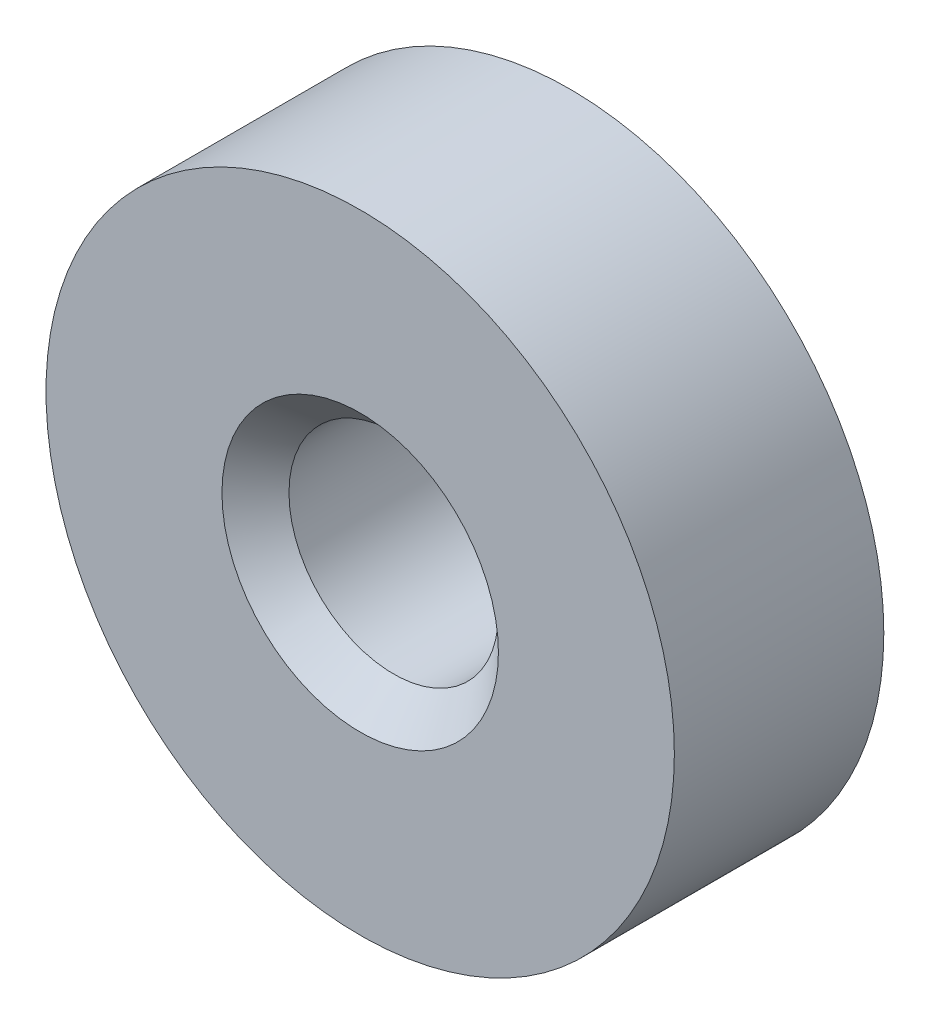
from build123d import *

# Parameters (mm, degrees)
SKETCH1_R           = 14.2875
SKETCH1_R_2         = 4.7625
BOSS_EXTRUDE1_DEPTH = 9.525
CHAMFER1_SIZE       = 1.524


with BuildPart() as part:
    # Sketch1 → Boss-Extrude1 (new body)
    with BuildSketch(Plane.XY):
        Circle(SKETCH1_R)
        Circle(SKETCH1_R_2, mode=Mode.SUBTRACT)
    extrude(amount=BOSS_EXTRUDE1_DEPTH)

    # Chamfer1
    chamfer1_edges = [part.edges().sort_by_distance(p)[0] for p in [
        (-4.7625, 0, 0),
        (-4.7625, 0, 9.525),
    ]]
    chamfer(chamfer1_edges, length=CHAMFER1_SIZE)


solid = part.part
